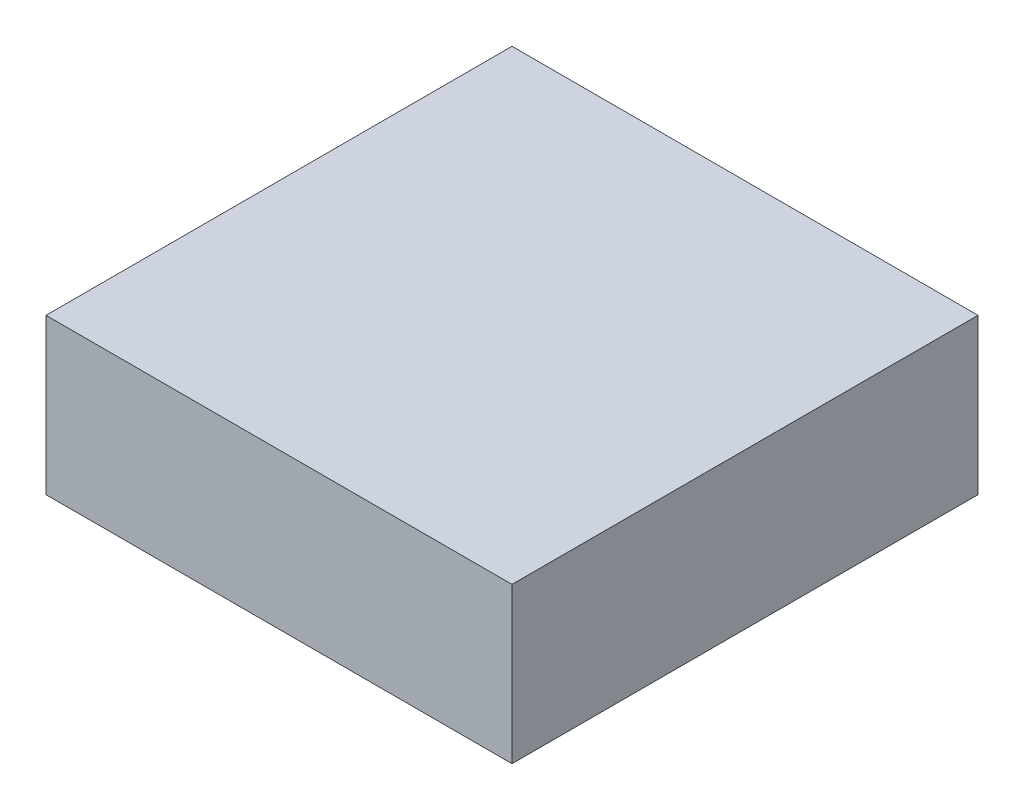
from build123d import *

# Parameters (mm, degrees)
SKETCH1_W           = 90
SKETCH1_H           = 90
BOSS_EXTRUDE1_DEPTH = 30


with BuildPart() as part:
    # Sketch1 → Boss-Extrude1 (new body)
    with BuildSketch(Plane(origin=(0, 0, 0), x_dir=(1, 0, 0), z_dir=(0, 1, 0))):
        with Locations((-44.334780029, -7.417896044)):
            Rectangle(SKETCH1_W, SKETCH1_H)
    extrude(amount=-BOSS_EXTRUDE1_DEPTH)


solid = part.part
